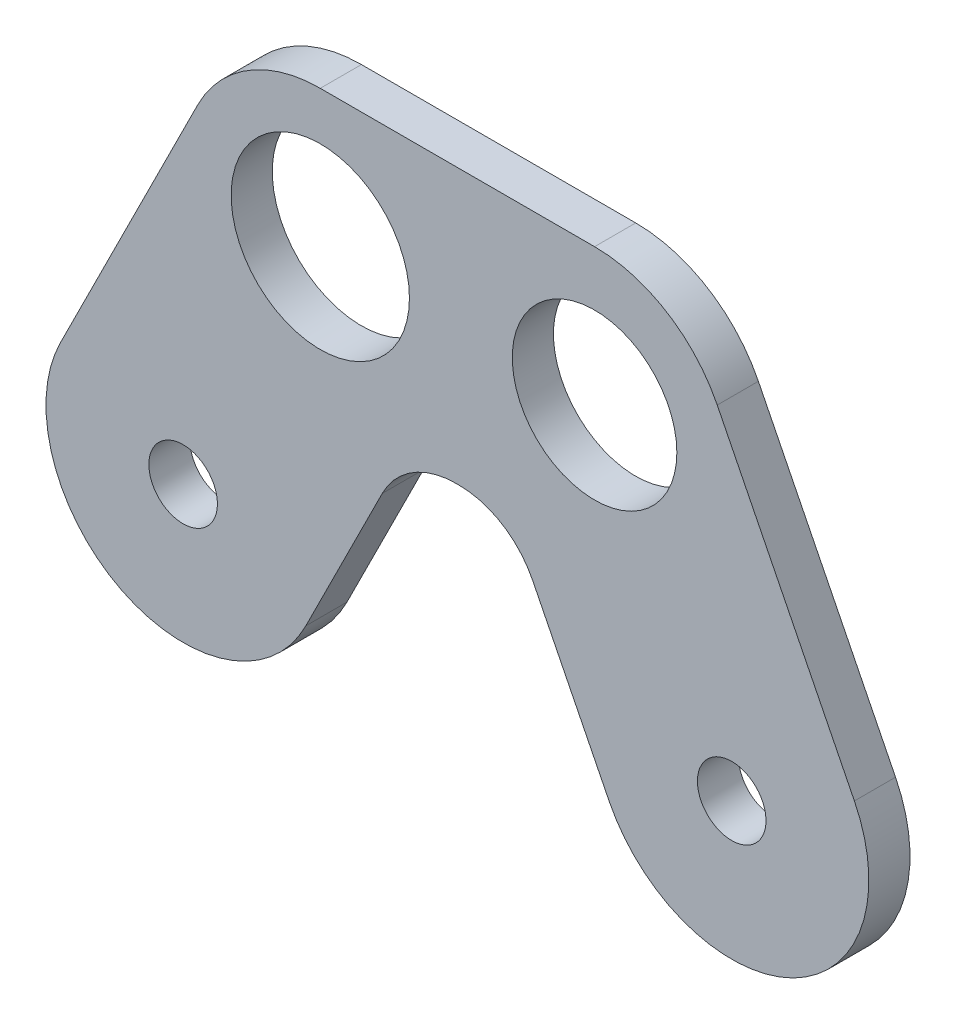
from build123d import *

# Parameters (mm, degrees)
ESQUISSE1_R        = 6.5
ESQUISSE1_R_2      = 6
ESQUISSE1_R_3      = 2.5
BOSS_EXTRU_1_DEPTH = 3
CONG_1_R           = 6


with BuildPart() as part:
    # Esquisse1 → Boss.-Extru.1 (new body)
    with BuildSketch(Plane.XY):
        with BuildLine():
            Line((0, 10), (20, 10))
            ThreePointArc((20, 10), (25.257311121, 8.506508084), (28.94427191, 4.472135955))
            Line((28.94427191, 4.472135955), (38.94427191, -15.527864045))
            ThreePointArc((38.94427191, -15.527864045), (34.472135955, -28.94427191), (21.05572809, -24.472135955))
            Line((21.05572809, -24.472135955), (13.819660113, -10))
            Line((13.819660113, -10), (6.180339887, -10))
            Line((6.180339887, -10), (-1.05572809, -24.472135955))
            ThreePointArc((-1.05572809, -24.472135955), (-14.472135955, -28.94427191), (-18.94427191, -15.527864045))
            Line((-18.94427191, -15.527864045), (-8.94427191, 4.472135955))
            ThreePointArc((-8.94427191, 4.472135955), (-5.257311121, 8.506508084), (0, 10))
        make_face()
        Circle(ESQUISSE1_R, mode=Mode.SUBTRACT)
        with Locations((20, 0)):
            Circle(ESQUISSE1_R_2, mode=Mode.SUBTRACT)
        with Locations((-10, -20)):
            Circle(ESQUISSE1_R_3, mode=Mode.SUBTRACT)
        with Locations((30, -20)):
            Circle(ESQUISSE1_R_3, mode=Mode.SUBTRACT)
    extrude(amount=BOSS_EXTRU_1_DEPTH)

    # Congé1
    cong_1_edges = [part.edges().sort_by_distance(p)[0] for p in [
        (6.180339887, -10, 1.5),
        (13.819660113, -10, 1.5),
    ]]
    fillet(cong_1_edges, radius=CONG_1_R)


solid = part.part
